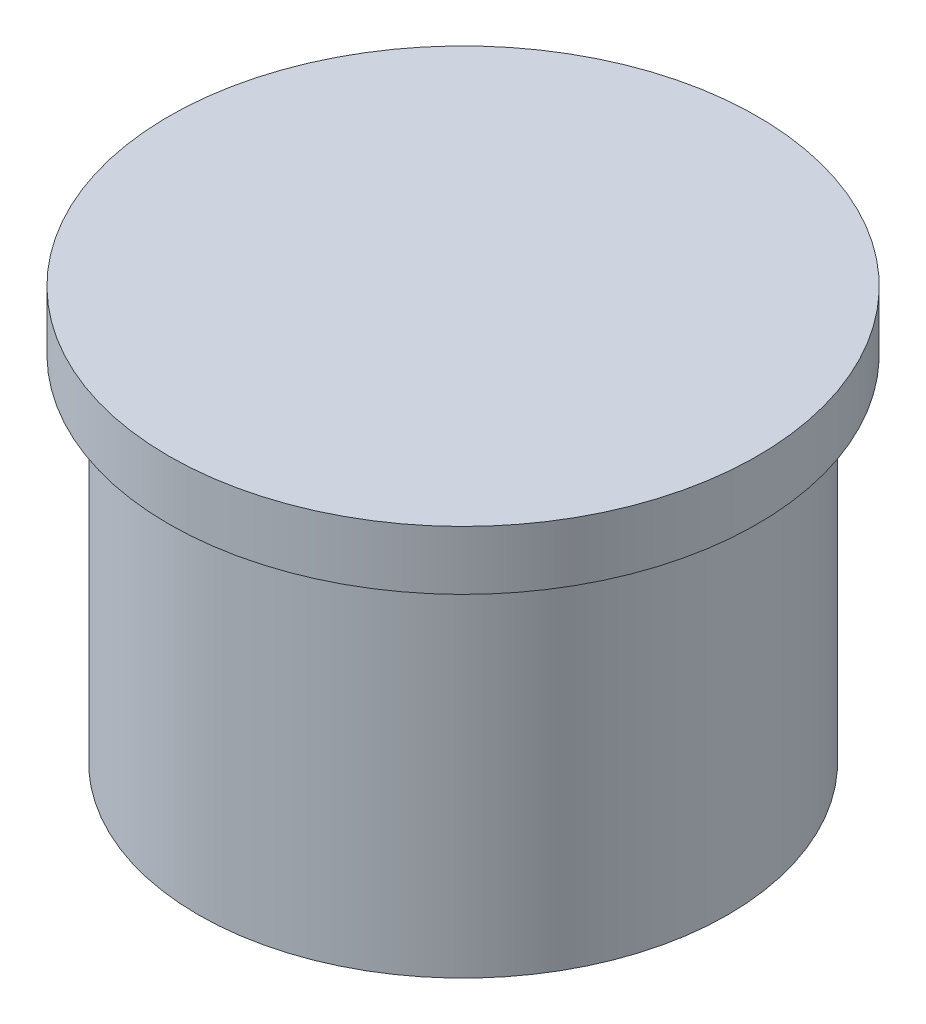
from build123d import *

# Parameters (mm, degrees)
SKETCH1_R           = 2.25
BOSS_EXTRUDE1_DEPTH = 3
SKETCH2_R           = 2.5
BOSS_EXTRUDE2_DEPTH = 0.5


with BuildPart() as part:
    # Sketch1 → Boss-Extrude1 (new body)
    with BuildSketch(Plane(origin=(0, 0, 0), x_dir=(1, 0, 0), z_dir=(0, 1, 0))):
        Circle(SKETCH1_R)
    extrude(amount=BOSS_EXTRUDE1_DEPTH)

    # Sketch2 → Boss-Extrude2 (add)
    with BuildSketch(Plane(origin=(0, 3, 0), x_dir=(1, 0, 0), z_dir=(0, 1, 0))):
        Circle(SKETCH2_R)
    extrude(amount=BOSS_EXTRUDE2_DEPTH)


solid = part.part
